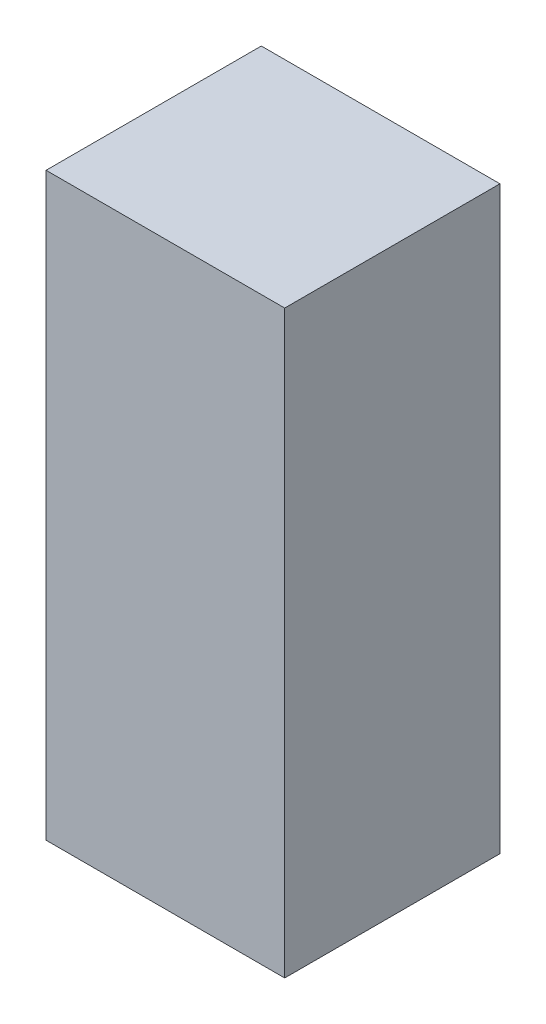
from build123d import *

# Parameters (mm, degrees)
SKETCH1_W           = 647.7
SKETCH1_H           = 584.2
BOSS_EXTRUDE1_DEPTH = 1574.8


with BuildPart() as part:
    # Sketch1 → Boss-Extrude1 (new body)
    with BuildSketch(Plane(origin=(0, 0, 0), x_dir=(1, 0, 0), z_dir=(0, 1, 0))):
        Rectangle(SKETCH1_W, SKETCH1_H)
    extrude(amount=BOSS_EXTRUDE1_DEPTH)


solid = part.part
